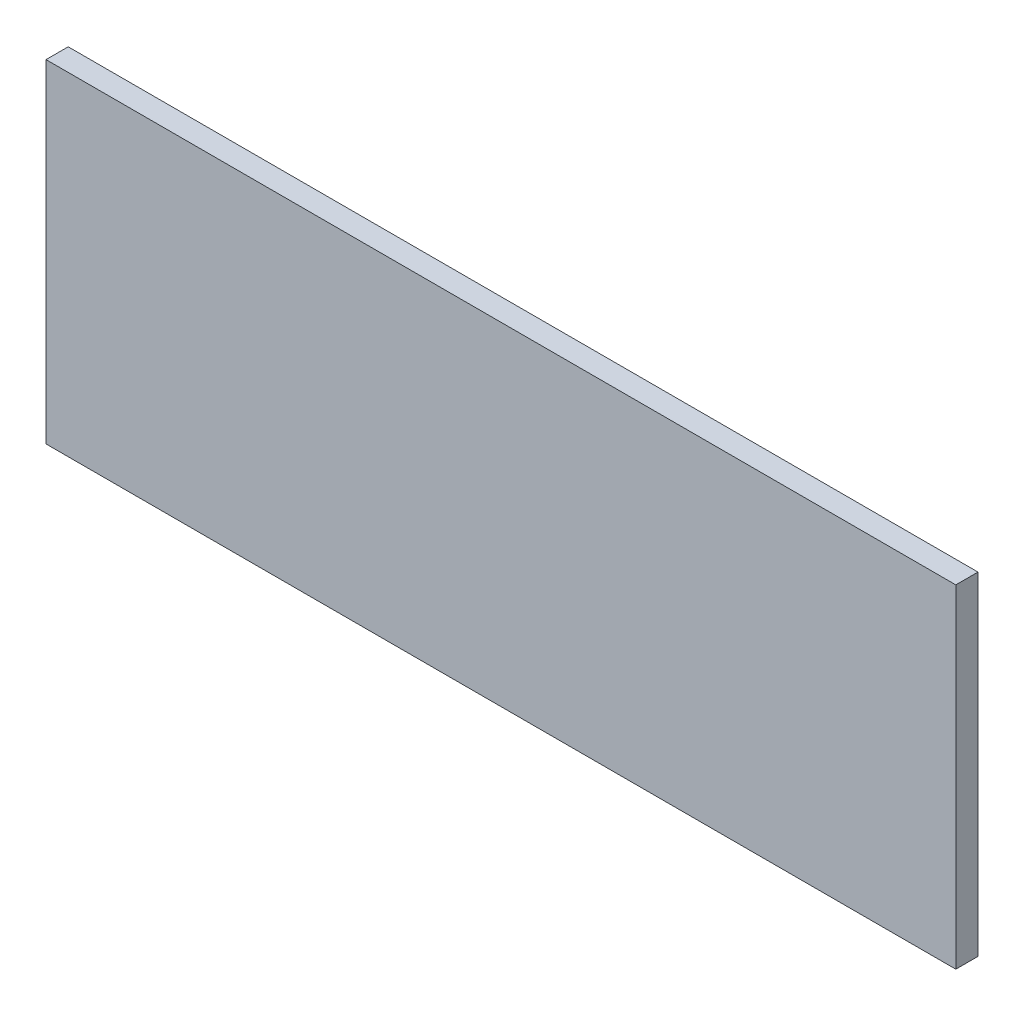
from build123d import *

# Parameters (mm, degrees)
SKETCH1_W           = 164
SKETCH1_H           = 60
BOSS_EXTRUDE1_DEPTH = 4


with BuildPart() as part:
    # Sketch1 → Boss-Extrude1 (new body)
    with BuildSketch(Plane.XY):
        Rectangle(SKETCH1_W, SKETCH1_H)
    extrude(amount=-BOSS_EXTRUDE1_DEPTH)


solid = part.part
